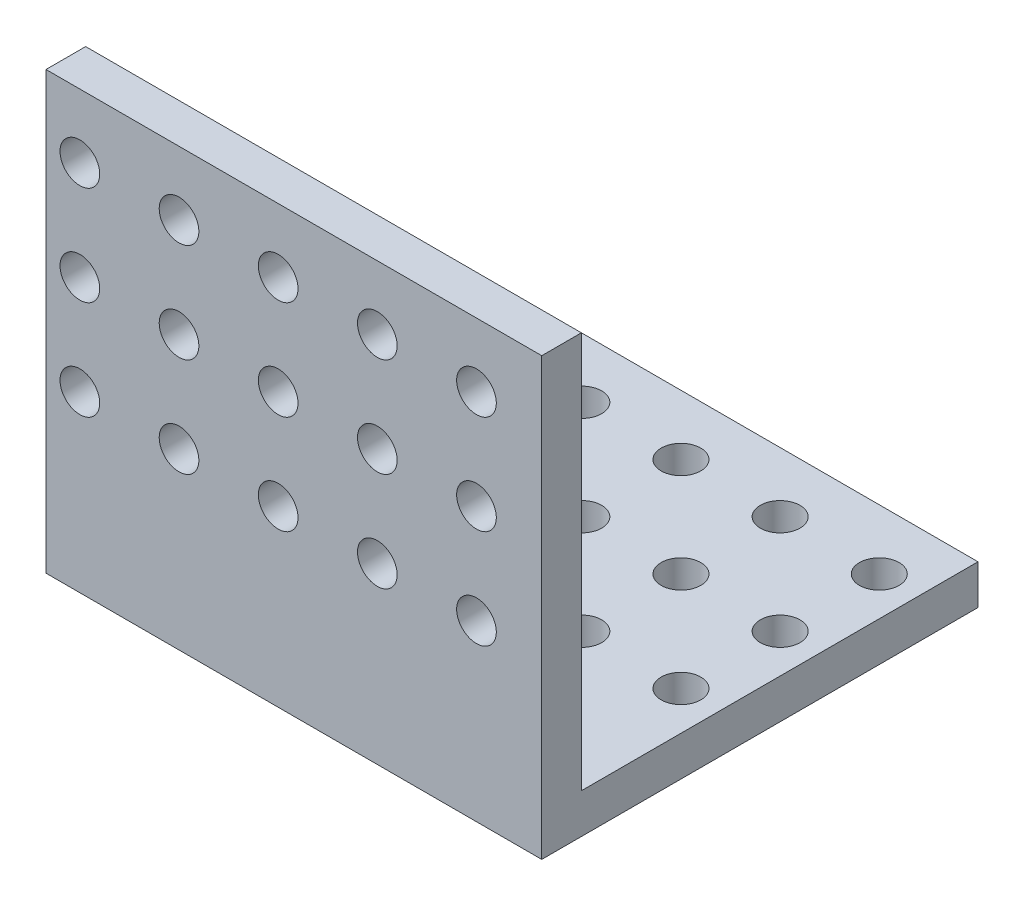
from build123d import *

# Parameters (mm, degrees)
EXTRUDE_THIN1_DEPTH = 25
SKETCH2_R           = 2
CUT_EXTRUDE1_DEPTH  = 5
SKETCH3_R           = 2
CUT_EXTRUDE2_DEPTH  = 5


with BuildPart() as part:
    # Sketch1 → Extrude-Thin1 (new body, symmetric)
    with BuildSketch(Plane(origin=(0, 0, 0), x_dir=(0, 0, -1), z_dir=(1, 0, 0))):
        Polygon((0, 40), (0, 0), (40, 0), (40, -4), (-4, -4), (-4, 40), align=None)
    extrude(amount=EXTRUDE_THIN1_DEPTH, both=True)

    # Sketch2 → Cut-Extrude1 (cut, through all)
    with BuildSketch(Plane(origin=(0, 0, 0), x_dir=(1, 0, 0), z_dir=(0, 1, 0))):
        with Locations((-18.910875839, 33.953285117)):
            Circle(SKETCH2_R)
        with Locations((-8.910875839, 33.953285117)):
            Circle(SKETCH2_R)
        with Locations((1.089124161, 33.953285117)):
            Circle(SKETCH2_R)
        with Locations((11.089124161, 33.953285117)):
            Circle(SKETCH2_R)
        with Locations((21.089124161, 33.953285117)):
            Circle(SKETCH2_R)
        with Locations((-8.910875839, 23.953285117)):
            Circle(SKETCH2_R)
        with Locations((1.089124161, 23.953285117)):
            Circle(SKETCH2_R)
        with Locations((11.089124161, 23.953285117)):
            Circle(SKETCH2_R)
        with Locations((21.089124161, 23.953285117)):
            Circle(SKETCH2_R)
        with Locations((-8.910875839, 13.953285117)):
            Circle(SKETCH2_R)
        with Locations((1.089124161, 13.953285117)):
            Circle(SKETCH2_R)
        with Locations((11.089124161, 13.953285117)):
            Circle(SKETCH2_R)
        with Locations((21.089124161, 13.953285117)):
            Circle(SKETCH2_R)
        with Locations((-18.910875839, 23.953285117)):
            Circle(SKETCH2_R)
        with Locations((-18.910875839, 13.953285117)):
            Circle(SKETCH2_R)
    extrude(amount=-CUT_EXTRUDE1_DEPTH, mode=Mode.SUBTRACT)

    # Sketch3 → Cut-Extrude2 (cut, through all)
    with BuildSketch(Plane(origin=(0, 0, 0), x_dir=(-1, 0, 0), z_dir=(0, 0, -1))):
        with Locations((-18.416248434, 33.561450044)):
            Circle(SKETCH3_R)
        with Locations((-8.416248434, 33.561450044)):
            Circle(SKETCH3_R)
        with Locations((1.583751566, 33.561450044)):
            Circle(SKETCH3_R)
        with Locations((11.583751566, 33.561450044)):
            Circle(SKETCH3_R)
        with Locations((21.583751566, 33.561450044)):
            Circle(SKETCH3_R)
        with Locations((-8.416248434, 23.561450044)):
            Circle(SKETCH3_R)
        with Locations((1.583751566, 23.561450044)):
            Circle(SKETCH3_R)
        with Locations((11.583751566, 23.561450044)):
            Circle(SKETCH3_R)
        with Locations((21.583751566, 23.561450044)):
            Circle(SKETCH3_R)
        with Locations((-8.416248434, 13.561450044)):
            Circle(SKETCH3_R)
        with Locations((1.583751566, 13.561450044)):
            Circle(SKETCH3_R)
        with Locations((11.583751566, 13.561450044)):
            Circle(SKETCH3_R)
        with Locations((21.583751566, 13.561450044)):
            Circle(SKETCH3_R)
        with Locations((-18.416248434, 23.561450044)):
            Circle(SKETCH3_R)
        with Locations((-18.416248434, 13.561450044)):
            Circle(SKETCH3_R)
    extrude(amount=-CUT_EXTRUDE2_DEPTH, mode=Mode.SUBTRACT)


solid = part.part
